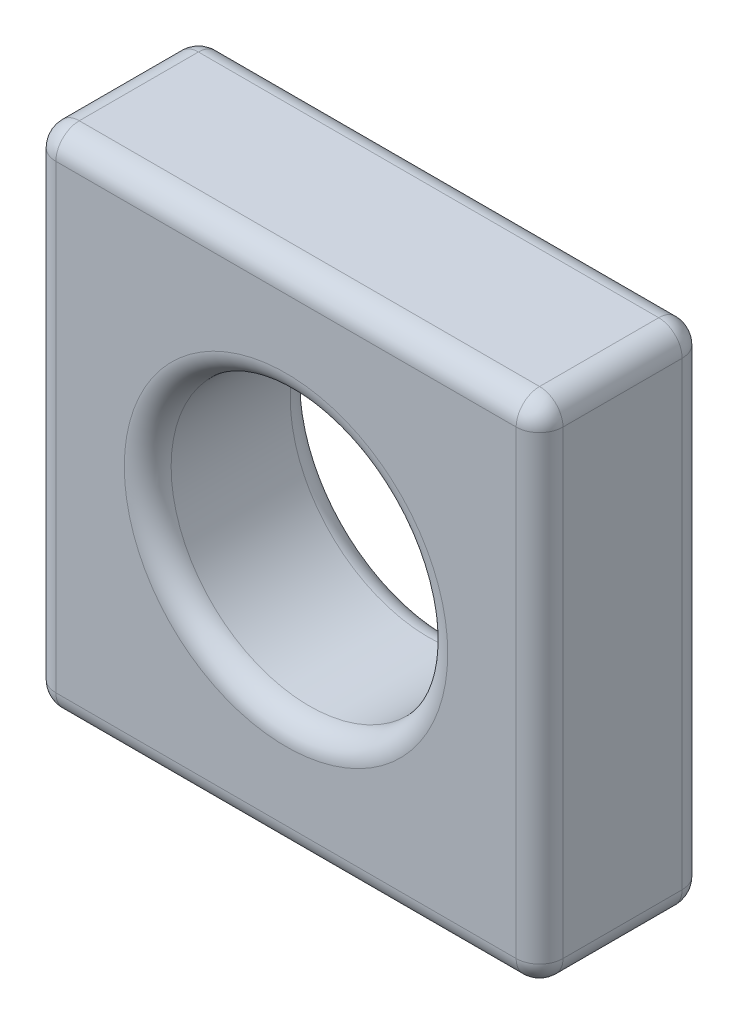
from build123d import *

# Parameters (mm, degrees)
SKETCH1_W           = 5.5
SKETCH1_H           = 5.5
SKETCH1_R           = 1.5
BOSS_EXTRUDE1_DEPTH = 1.8
FILLET1_R           = 0.254


with BuildPart() as part:
    # Sketch1 → Boss-Extrude1 (new body)
    with BuildSketch(Plane.XY):
        with Locations((2.75, 2.75)):
            Rectangle(SKETCH1_W, SKETCH1_H)
        with Locations((2.75, 2.75)):
            Circle(SKETCH1_R, mode=Mode.SUBTRACT)
    extrude(amount=BOSS_EXTRUDE1_DEPTH)

    # Fillet1
    fillet1_edges = [part.edges().sort_by_distance(p)[0] for p in [
        (5.5, 2.75, 1.8),
        (1.25, 2.75, 0),
        (1.25, 2.75, 1.8),
        (2.75, 5.5, 1.8),
        (0, 2.75, 1.8),
        (2.75, 5.5, 0),
        (5.5, 2.75, 0),
        (2.75, 0, 0),
        (0, 2.75, 0),
        (2.75, 0, 1.8),
        (0, 5.5, 0.9),
        (5.5, 5.5, 0.9),
        (5.5, 0, 0.9),
        (0, 0, 0.9),
    ]]
    fillet(fillet1_edges, radius=FILLET1_R)


solid = part.part
